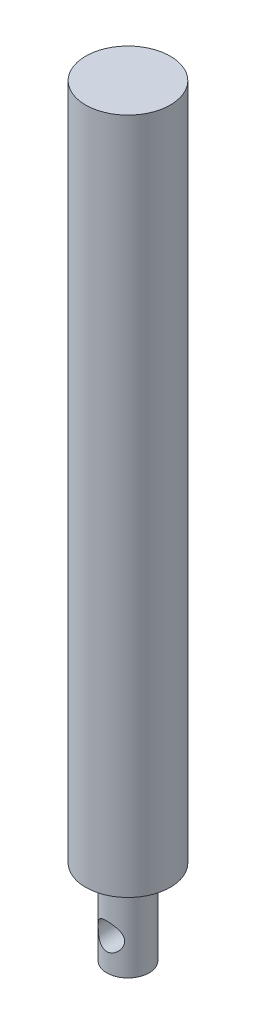
from build123d import *

# Parameters (mm, degrees)
SKETCH1_R               = 12.7
BOSS_EXTRUDE1_DEPTH     = 203.2
SKETCH1_3_R             = 6.35
BOSS_EXTRUDE2_DEPTH     = 25.4
CUT_EXTRUDE2_DEPTH      = 204.992205733
CUT_EXTRUDE2_DEPTH_BACK = 204.992205733
SKETCH3_R               = 3.96875


with BuildPart() as part:
    # Sketch1 → Boss-Extrude1 (new body)
    with BuildSketch(Plane(origin=(0, 0, 0), x_dir=(1, 0, 0), z_dir=(0, 1, 0))):
        Circle(SKETCH1_R)
    extrude(amount=BOSS_EXTRUDE1_DEPTH)

    # Sketch1_3 → Boss-Extrude2 (add)
    with BuildSketch(Plane(origin=(0, 0, 0), x_dir=(1, 0, 0), z_dir=(0, 1, 0))):
        Circle(SKETCH1_3_R)
    extrude(amount=-BOSS_EXTRUDE2_DEPTH)

    # Sketch3 → Cut-Extrude2 (cut, two sides: drawn at the far end of the back side and taken through both)
    with BuildSketch(Plane.XY.offset(-CUT_EXTRUDE2_DEPTH_BACK)):
        with Locations((0, -15.875)):
            Circle(SKETCH3_R)
    extrude(amount=CUT_EXTRUDE2_DEPTH + CUT_EXTRUDE2_DEPTH_BACK, mode=Mode.SUBTRACT)


solid = part.part
